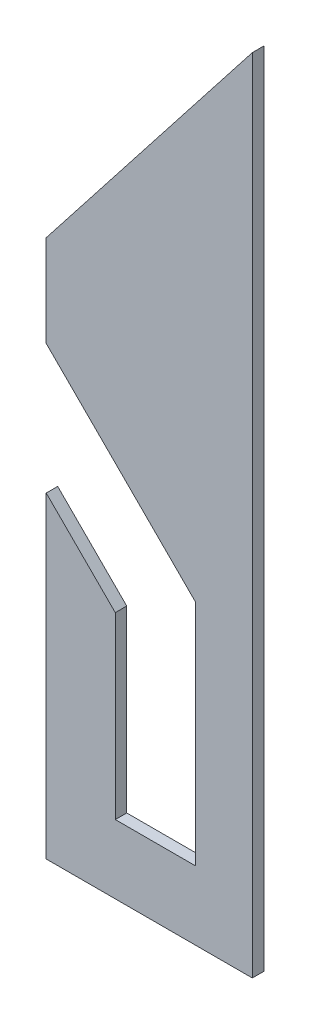
from build123d import *

# Parameters (mm, degrees)
BOSS_EXTRUDE1_DEPTH = 5


with BuildPart() as part:
    # Sketch1 → Boss-Extrude1 (new body)
    with BuildSketch(Plane.XY):
        Polygon((90, 350), (0, 235), (0, 195), (65.158984127, 129.841015873), (65.158984127, 30), (30.158984127, 30), (30.158984127, 108.272473378), (0, 138.431457505), (0, 0), (90, 0), align=None)
    extrude(amount=BOSS_EXTRUDE1_DEPTH)


solid = part.part
